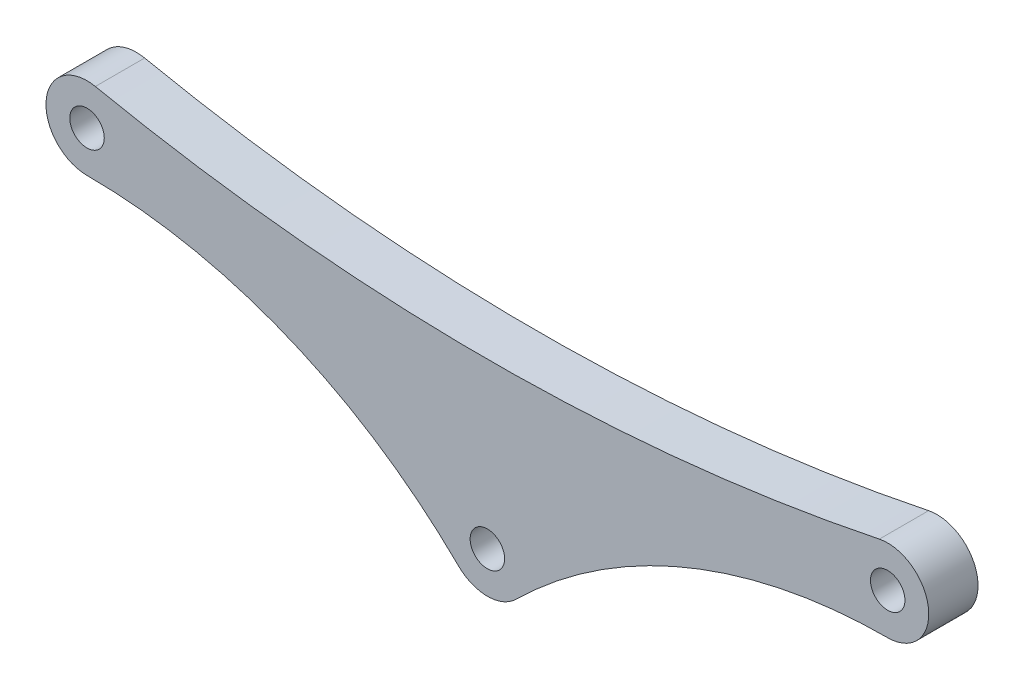
from build123d import *

# Parameters (mm, degrees)
SKETCH1_R           = 2.1
BOSS_EXTRUDE1_DEPTH = 6


with BuildPart() as part:
    # Sketch1 → Boss-Extrude1 (new body)
    with BuildSketch(Plane.XY):
        with BuildLine():
            ThreePointArc((3.511536297, -3.559369724), (24.301233146, 10.179806707), (48.75, 15))
            ThreePointArc((48.75, 15), (53.723907193, 20.510144327), (47.735035784, 24.895901106))
            ThreePointArc((47.735035784, 24.895901106), (0, 20), (-47.735035784, 24.895901106))
            ThreePointArc((-47.735035784, 24.895901106), (-53.723907193, 20.510144327), (-48.75, 15))
            ThreePointArc((-48.75, 15), (-24.301233146, 10.179806707), (-3.511536297, -3.559369724))
            ThreePointArc((-3.511536297, -3.559369724), (0, -5), (3.511536297, -3.559369724))
        make_face()
        Circle(SKETCH1_R, mode=Mode.SUBTRACT)
        with Locations((-48.75, 20)):
            Circle(SKETCH1_R, mode=Mode.SUBTRACT)
        with Locations((48.75, 20)):
            Circle(SKETCH1_R, mode=Mode.SUBTRACT)
    extrude(amount=BOSS_EXTRUDE1_DEPTH)


solid = part.part
